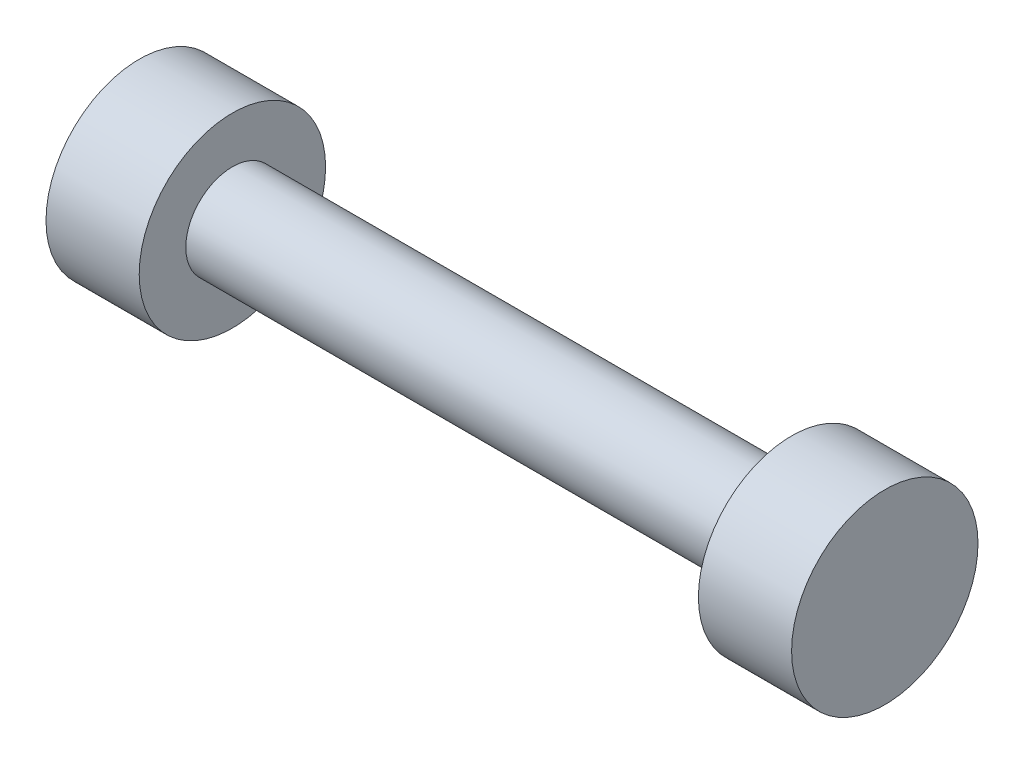
from build123d import *


with BuildPart() as part:
    # Croquis1 → Revolución1 (revolve)
    with BuildSketch(Plane(origin=(0, 0, 0), x_dir=(1, 0, 0), z_dir=(0, 1, 0))):
        Polygon((15, 2.5), (15, 5), (20, 5), (20, 0), (-20, 0), (-20, 5), (-15, 5), (-15, 2.5), align=None)
    revolve(axis=Axis((-39.502018508, 0, 0), (1, 0, 0)))


solid = part.part
